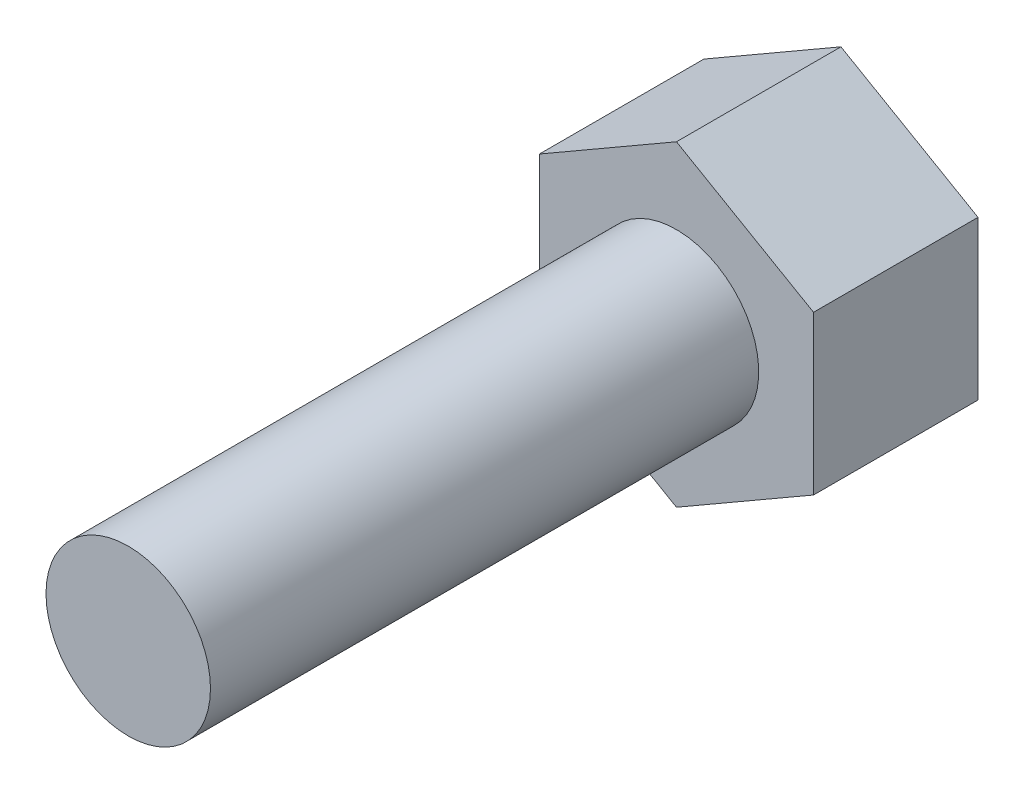
from build123d import *

# Parameters (mm, degrees)
SKETCH1_R           = 1.5
BOSS_EXTRUDE1_DEPTH = 10
BOSS_EXTRUDE2_DEPTH = 3


with BuildPart() as part:
    # Sketch1 → Boss-Extrude1 (new body)
    with BuildSketch(Plane.XY):
        with Locations((-63.49476159, 14.978708134)):
            Circle(SKETCH1_R)
    extrude(amount=BOSS_EXTRUDE1_DEPTH)

    # Sketch2 → Boss-Extrude2 (add)
    with BuildSketch(Plane(origin=(0, 0, 0), x_dir=(-1, 0, 0), z_dir=(0, 0, -1))):
        Polygon((63.49476159, 12.091956788), (65.99476159, 13.535332461), (65.99476159, 16.422083807), (63.49476159, 17.86545948), (60.99476159, 16.422083807), (60.99476159, 13.535332461), align=None)
    extrude(amount=BOSS_EXTRUDE2_DEPTH)


solid = part.part
